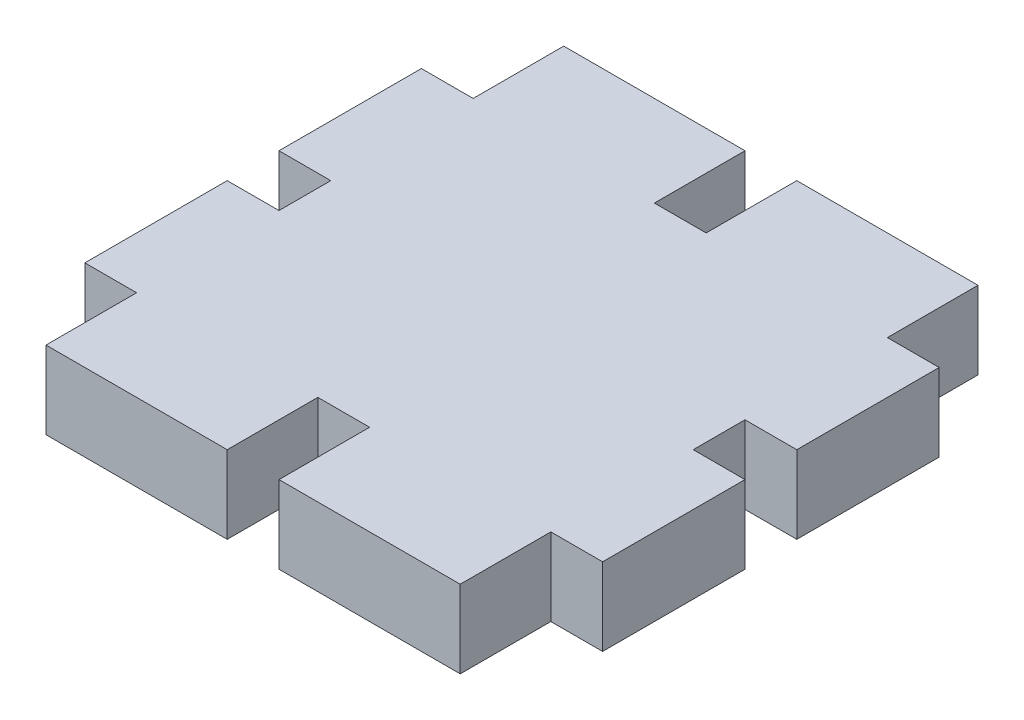
from build123d import *

# Parameters (mm, degrees)
BOSS_EXTRUDE1_DEPTH = 3


with BuildPart() as part:
    # Sketch1 → Boss-Extrude1 (new body)
    with BuildSketch(Plane(origin=(0, 0, 0), x_dir=(1, 0, 0), z_dir=(0, 1, 0))):
        Polygon((1, 16.5), (1, 20), (8, 20), (8, 16.5), (10, 16.5), (10, 11), (8, 11), (8, 9), (10, 9), (10, 3.5), (8, 3.5), (8, 0), (1, 0), (1, 3.5), (-1, 3.5), (-1, 0), (-8, 0), (-8, 3.5), (-10, 3.5), (-10, 9), (-8, 9), (-8, 11), (-10, 11), (-10, 16.5), (-8, 16.5), (-8, 20), (-1, 20), (-1, 16.5), align=None)
    extrude(amount=BOSS_EXTRUDE1_DEPTH)


solid = part.part
